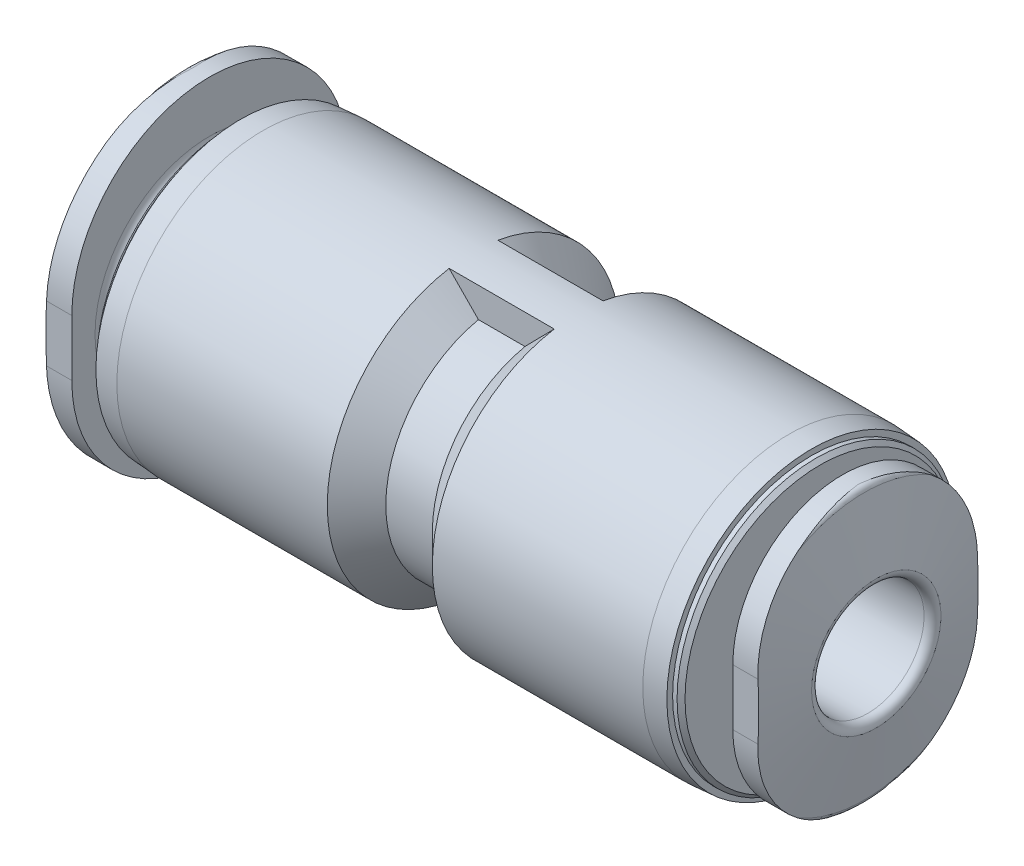
from build123d import *

# Parameters (mm, degrees)
SKIZZE2_W                            = 14.16
SKIZZE2_H                            = 14.16
SCHNITT_LINEAR_AUSTRAGEN1_DEPTH      = 1.2
SKIZZE3_W                            = 14.16
SKIZZE3_H                            = 14.16
SCHNITT_LINEAR_AUSTRAGEN2_DEPTH      = 1.2
AUFSATZ_LINEAR_AUSTRAGEN1_DEPTH      = 1.8675
AUFSATZ_LINEAR_AUSTRAGEN1_DEPTH_BACK = 1.8675
SKIZZE4_R                            = 3.12


with BuildPart() as part:
    # Skizze1 → Rotation1 (revolve)
    with BuildSketch(Plane(origin=(0, 0, 0), x_dir=(1, 0, 0), z_dir=(0, 1, 0))):
        with BuildLine():
            Line((-12.45, 0), (-12.45, 3.3))
            Line((-12.45, 3.3), (-12.020691475, 5.734729636))
            ThreePointArc((-12.020691475, 5.734729636), (-11.952287446, 5.853208889), (-11.823729924, 5.9))
            Line((-11.823729924, 5.9), (-11.25, 5.9))
            Line((-11.25, 5.9), (-11.25, 4.075))
            ThreePointArc((-11.25, 4.075), (-11.140165043, 3.809834957), (-10.875, 3.7))
            Line((-10.875, 3.7), (-10.45, 3.7))
            Line((-10.45, 3.7), (-10.45, 4.798578644))
            Line((-10.45, 4.798578644), (-10.308578644, 4.94))
            Line((-10.308578644, 4.94), (-10.15, 4.94))
            Line((-10.15, 4.94), (-10.15, 5.14405855))
            Line((-10.15, 5.14405855), (-9.35, 5.2))
            Line((-9.35, 5.2), (-1.8675, 5.2))
            Line((-1.8675, 5.2), (-0.8275, 4.16))
            Line((-0.8275, 4.16), (0.8275, 4.16))
            Line((0.8275, 4.16), (1.8675, 5.2))
            Line((1.8675, 5.2), (9.35, 5.2))
            Line((9.35, 5.2), (10.15, 5.14405855))
            Line((10.15, 5.14405855), (10.15, 4.94))
            Line((10.15, 4.94), (10.308578644, 4.94))
            Line((10.308578644, 4.94), (10.45, 4.798578644))
            Line((10.45, 4.798578644), (10.45, 2.5))
            Line((10.45, 2.5), (10.875, 2.5))
            ThreePointArc((10.875, 2.5), (11.140165043, 2.609834957), (11.25, 2.875))
            Line((11.25, 2.875), (11.25, 4.9))
            Line((11.25, 4.9), (11.823729924, 4.9))
            ThreePointArc((11.823729924, 4.9), (11.952287446, 4.853208889), (12.020691475, 4.734729636))
            Line((12.020691475, 4.734729636), (12.45, 2.3))
            Line((12.45, 2.3), (12.45, 0))
            Line((12.45, 0), (-12.45, 0))
        make_face()
    revolve(axis=Axis((12.45, 0, 0), (-1, 0, 0)))

    # Skizze2 → Schnitt-Linear austragen1 (cut)
    with BuildSketch(Plane(origin=(12.45, 0, 0), x_dir=(0, 0, -1), z_dir=(1, 0, 0))):
        Rectangle(SKIZZE2_W, SKIZZE2_H)
        with BuildLine():
            Line((3.9, -1), (3.9, 1))
            ThreePointArc((3.9, 1), (0, 4.9), (-3.9, 1))
            Line((-3.9, 1), (-3.9, -1))
            ThreePointArc((-3.9, -1), (0, -4.9), (3.9, -1))
        make_face(mode=Mode.SUBTRACT)
    extrude(amount=-SCHNITT_LINEAR_AUSTRAGEN1_DEPTH, mode=Mode.SUBTRACT)

    # Skizze3 → Schnitt-Linear austragen2 (cut)
    with BuildSketch(Plane(origin=(-12.45, 0, 0), x_dir=(0, 0, -1), z_dir=(1, 0, 0))):
        Rectangle(SKIZZE3_W, SKIZZE3_H)
        with BuildLine():
            Line((4.9, -1), (4.9, 1))
            ThreePointArc((4.9, 1), (0, 5.9), (-4.9, 1))
            Line((-4.9, 1), (-4.9, -1))
            ThreePointArc((-4.9, -1), (0, -5.9), (4.9, -1))
        make_face(mode=Mode.SUBTRACT)
    extrude(amount=SCHNITT_LINEAR_AUSTRAGEN2_DEPTH, mode=Mode.SUBTRACT)

    # Skizze4 → Aufsatz-Linear austragen1 (add, two sides: drawn at the far end of the back side and taken through both)
    with BuildSketch(Plane(origin=(0, 0, 0), x_dir=(0, 0, -1), z_dir=(1, 0, 0)).offset(-AUFSATZ_LINEAR_AUSTRAGEN1_DEPTH_BACK)):
        with BuildLine():
            Line((-0.866666667, -3.802484568), (-0.866666667, -5.127269145))
            ThreePointArc((-0.866666667, -5.127269145), (0, -5.2), (0.866666667, -5.127269145))
            Line((0.866666667, -5.127269145), (0.866666667, -3.802484568))
            ThreePointArc((0.866666667, -3.802484568), (3.9, 0), (0.866666667, 3.802484568))
            Line((0.866666667, 3.802484568), (0.866666667, 5.127269145))
            ThreePointArc((0.866666667, 5.127269145), (0, 5.2), (-0.866666667, 5.127269145))
            Line((-0.866666667, 5.127269145), (-0.866666667, 3.802484568))
            ThreePointArc((-0.866666667, 3.802484568), (-3.9, 0), (-0.866666667, -3.802484568))
        make_face()
        Circle(SKIZZE4_R, mode=Mode.SUBTRACT)
    extrude(amount=AUFSATZ_LINEAR_AUSTRAGEN1_DEPTH + AUFSATZ_LINEAR_AUSTRAGEN1_DEPTH_BACK)

    # Skizze5 → Schnitt-Rotation1 (revolve, cut)
    with BuildSketch(Plane.XY):
        with BuildLine():
            Line((-12.45, 0), (-12.45, 3.3))
            ThreePointArc((-12.45, 3.3), (-12.362132034, 3.087867966), (-12.15, 3))
            Line((-12.15, 3), (-0.85, 3))
            Line((-0.85, 3), (-0.85, 1.5))
            Line((-0.85, 1.5), (0.85, 1.5))
            Line((0.85, 1.5), (0.85, 2))
            Line((0.85, 2), (12.15, 2))
            ThreePointArc((12.15, 2), (12.362132034, 2.087867966), (12.45, 2.3))
            Line((12.45, 2.3), (12.45, 0))
            Line((12.45, 0), (-12.45, 0))
        make_face()
    revolve(axis=Axis((12.45, 0, 0), (-1, 0, 0)), mode=Mode.SUBTRACT)


solid = part.part
